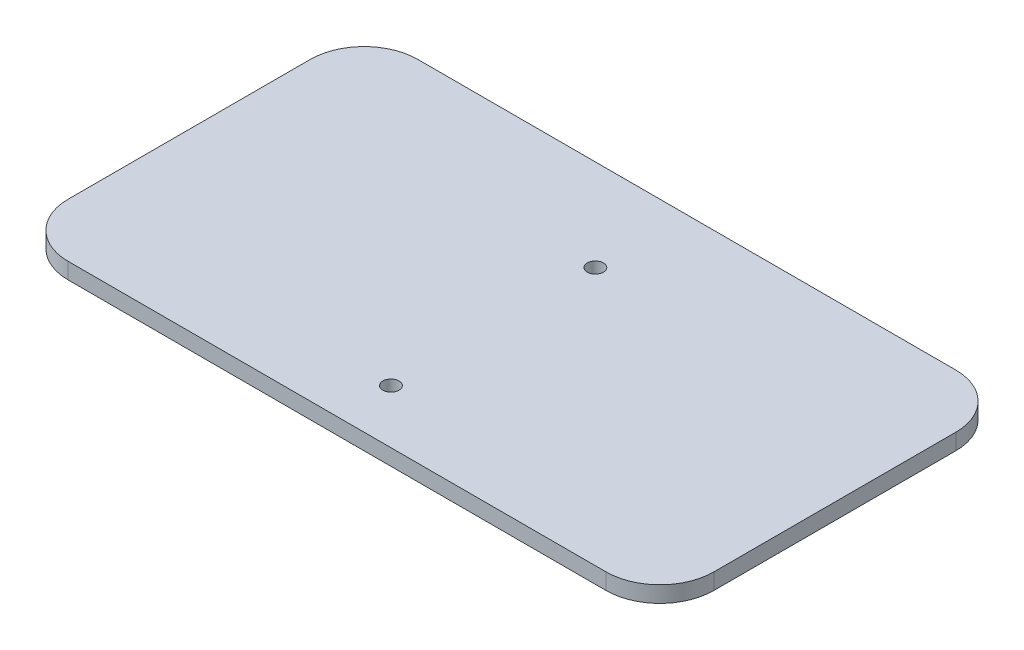
from build123d import *

# Parameters (mm, degrees)
SKETCH1_R           = 1.5
BOSS_EXTRUDE1_DEPTH = 3


with BuildPart() as part:
    # Sketch1 → Boss-Extrude1 (new body)
    with BuildSketch(Plane(origin=(0, 0, 0), x_dir=(1, 0, 0), z_dir=(0, 1, 0))):
        with BuildLine():
            Line((-50, -10), (50, -10))
            ThreePointArc((50, -10), (57.071067812, -7.071067812), (60, 0))
            Line((60, 0), (60, 45))
            ThreePointArc((60, 45), (57.071067812, 52.071067812), (50, 55))
            Line((50, 55), (-50, 55))
            ThreePointArc((-50, 55), (-57.071067812, 52.071067812), (-60, 45))
            Line((-60, 45), (-60, 0))
            ThreePointArc((-60, 0), (-57.071067812, -7.071067812), (-50, -10))
        make_face()
        Circle(SKETCH1_R, mode=Mode.SUBTRACT)
        with Locations((0, 38)):
            Circle(SKETCH1_R, mode=Mode.SUBTRACT)
    extrude(amount=BOSS_EXTRUDE1_DEPTH)


solid = part.part
